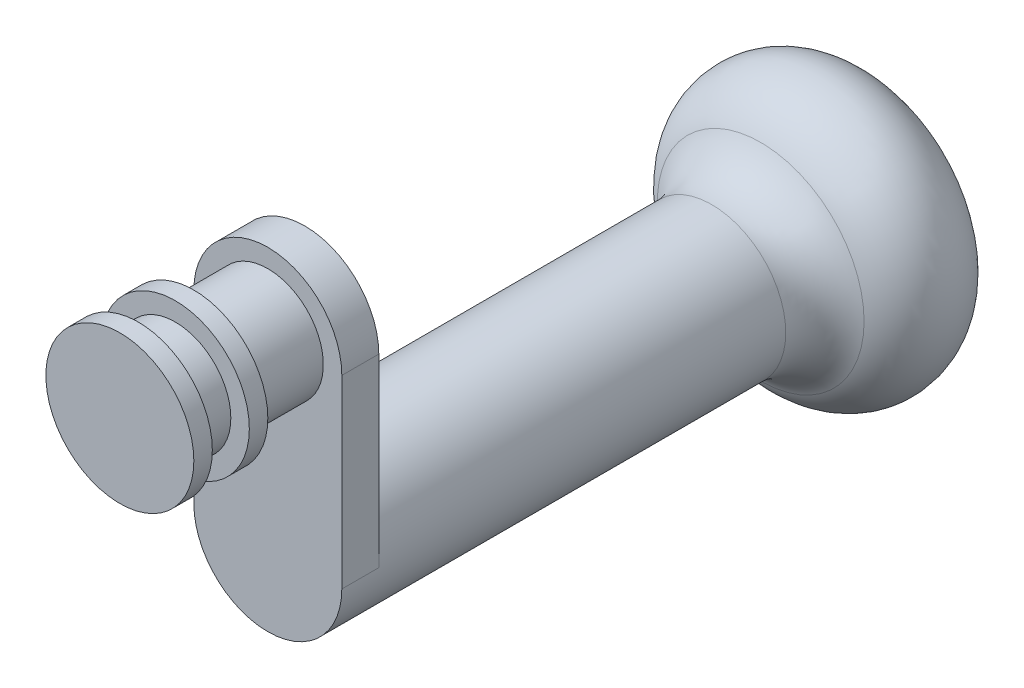
from build123d import *

# Parameters (mm, degrees)
SKETCH1_R           = 7.5
BOSS_EXTRUDE1_DEPTH = 25
SKETCH2_R           = 10
BOSS_EXTRUDE2_DEPTH = 2.5
BOSS_EXTRUDE3_START = -7.5
SKETCH2_2_R         = 10
BOSS_EXTRUDE3_DEPTH = 2.5
BOSS_EXTRUDE4_START = -5
BOSS_EXTRUDE4_DEPTH = 5
SKETCH5_R           = 10
BOSS_EXTRUDE5_DEPTH = 57.5


with BuildPart() as part:
    # Sketch1 → Boss-Extrude1 (new body)
    with BuildSketch(Plane.XY):
        Circle(SKETCH1_R)
    extrude(amount=BOSS_EXTRUDE1_DEPTH)

    # Sketch2 → Boss-Extrude2 (add)
    with BuildSketch(Plane.XY.offset(25)):
        Circle(SKETCH2_R)
    extrude(amount=-BOSS_EXTRUDE2_DEPTH)

    # Sketch2_2 → Boss-Extrude3 (add)
    with BuildSketch(Plane.XY.offset(25).offset(BOSS_EXTRUDE3_START)):
        Circle(SKETCH2_2_R)
    extrude(amount=-BOSS_EXTRUDE3_DEPTH)

    # Sketch4 → Boss-Extrude4 (add)
    with BuildSketch(Plane(origin=(0, 0, 0), x_dir=(-1, 0, 0), z_dir=(0, 0, -1)).offset(BOSS_EXTRUDE4_START)):
        with BuildLine():
            Line((-10, 0), (-10, -25))
            ThreePointArc((-10, -25), (0, -35), (10, -25))
            Line((10, -25), (10, 0))
            ThreePointArc((10, 0), (0, 10), (-10, 0))
        make_face()
    extrude(amount=BOSS_EXTRUDE4_DEPTH)

    # Sketch5 → Boss-Extrude5 (add)
    with BuildSketch(Plane.XY.offset(5)):
        with Locations((0, -25)):
            Circle(SKETCH5_R)
    extrude(amount=-BOSS_EXTRUDE5_DEPTH)

    # Sketch6 → Revolve1 (revolve)
    with BuildSketch(Plane(origin=(0, 0, 0), x_dir=(0, 0, -1), z_dir=(1, 0, 0))):
        with BuildLine():
            Line((52.5, -25), (77.5, -25))
            Line((77.5, -25), (77.5, -15))
            ThreePointArc((77.5, -15), (71.108894336, -6.814422655), (61.617647059, -11.029411765))
            ThreePointArc((61.617647059, -11.029411765), (58.858718166, -13.931196943), (55, -15))
            Line((55, -15), (52.5, -15))
            Line((52.5, -15), (52.5, -25))
        make_face()
    revolve(axis=Axis((0, -25, -52.5), (0, 0, -1)))


solid = part.part
